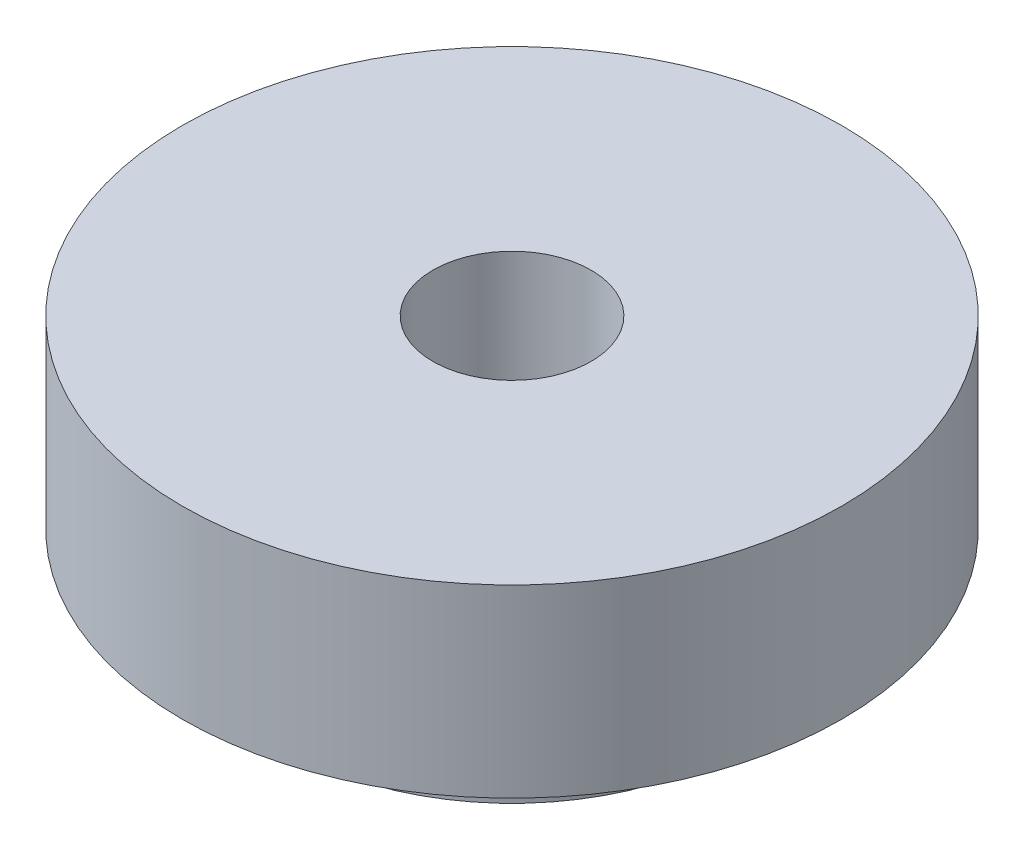
from build123d import *


with BuildPart() as part:
    # Sketch1 → Revolve1 (revolve)
    with BuildSketch(Plane.XY, mode=Mode.PRIVATE) as revolve1_sk:
        Polygon((2.159, 0), (3.175, 0), (3.175, 1.778), (0.762, 1.778), (0.762, -0.762), (2.159, -0.762), align=None)
    revolve(revolve1_sk.sketch.rotate(Axis((0, 50.934334119, 0), (0, -1, 0)), 180), axis=Axis((0, 50.934334119, 0), (0, -1, 0)))  # turned: the seam where the file's is


solid = part.part
